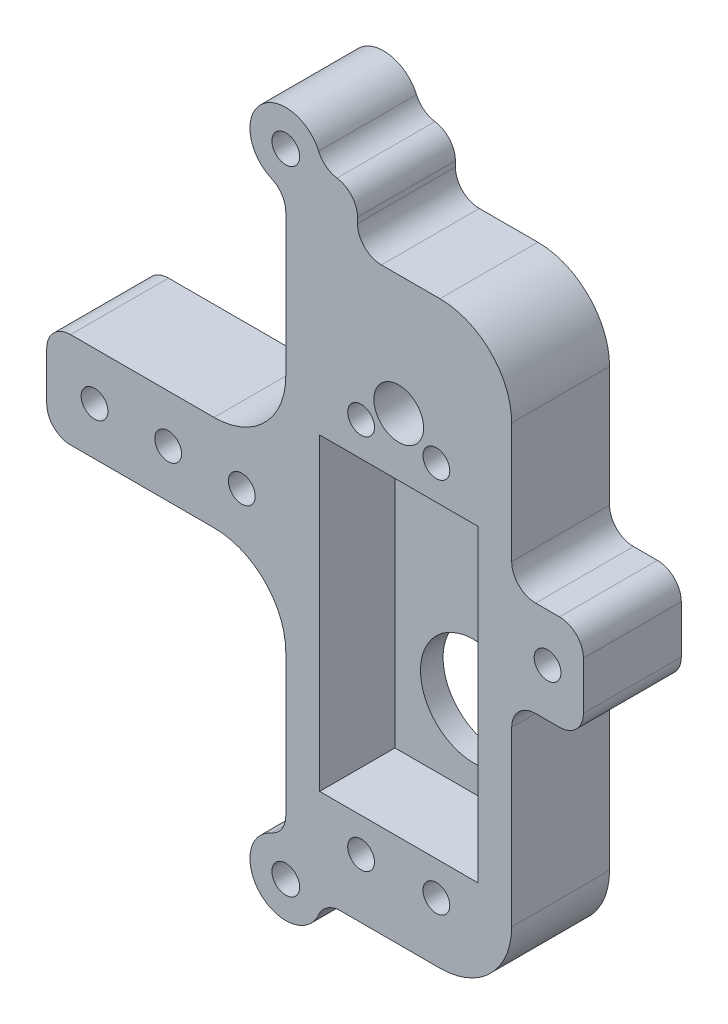
from build123d import *

# Parameters (mm, degrees)
SKETCH1_W               = 31.75
SKETCH1_H               = 12.7
SKETCH1_W_2             = 30
SKETCH1_H_2             = 7
BOSS_EXTRUDE1_DEPTH     = 13
SKETCH4_R               = 1.778
CUT_EXTRUDE3_DEPTH      = 14
SKETCH5_W               = 21
SKETCH5_H               = 41
CUT_EXTRUDE4_DEPTH      = 10
SKETCH6_R               = 7.112
CUT_EXTRUDE5_DEPTH      = 4
SKETCH7_W               = 31.75
SKETCH7_H               = 12.7
CUT_EXTRUDE6_DEPTH      = 6.35
SKETCH10_R              = 1.905
CUT_EXTRUDE8_DEPTH      = 14
SKETCH11_R              = 3.302
CUT_EXTRUDE9_DEPTH      = 9.525
SKETCH13_W              = 9.525
SKETCH13_H              = 12.7
SKETCH13_R              = 1.778
BOSS_EXTRUDE2_DEPTH     = 13
BOSS_EXTRUDE3_DEPTH     = 13
SKETCH18_R              = 1.8415
CUT_EXTRUDE10_DEPTH     = 14
FILLET1_R               = 9.525
FILLET2_R               = 3.175
SKETCH19_W              = 22.225
SKETCH19_H              = 12.7
BOSS_EXTRUDE4_DEPTH     = 7.62
SKETCH8_R               = 1.778
CUT_EXTRUDE7_DEPTH      = 7.35
CUT_EXTRUDE7_DEPTH_BACK = 17.78
FILLET3_R               = 3.175


with BuildPart() as part:
    # Sketch1 → Boss-Extrude1 (new body)
    with BuildSketch(Plane.XY):
        Polygon((31.75, 12.7), (31.75, 0), (31.75, -28.65), (61.75, -28.65), (61.75, 0), (61.75, 12.7), (61.75, 41.35), (31.75, 41.35), align=None)
        with Locations((15.875, 6.35)):
            Rectangle(SKETCH1_W, SKETCH1_H)
        with Locations((46.75, -32.15)):
            Rectangle(SKETCH1_W_2, SKETCH1_H_2)
    extrude(amount=BOSS_EXTRUDE1_DEPTH)

    # Sketch4 → Cut-Extrude3 (cut, through all)
    with BuildSketch(Plane.XY.offset(13)):
        with Locations((41.75, 22.199999832)):
            Circle(SKETCH4_R)
        with Locations((51.75, 22.199999832)):
            Circle(SKETCH4_R)
        with Locations((41.75, -27.800000168)):
            Circle(SKETCH4_R)
        with Locations((51.75, -27.800000168)):
            Circle(SKETCH4_R)
    extrude(amount=-CUT_EXTRUDE3_DEPTH, mode=Mode.SUBTRACT)

    # Sketch5 → Cut-Extrude4 (cut)
    with BuildSketch(Plane.XY.offset(13)):
        with Locations((46.75, -2.800000024)):
            Rectangle(SKETCH5_W, SKETCH5_H)
    extrude(amount=-CUT_EXTRUDE4_DEPTH, mode=Mode.SUBTRACT)

    # Sketch6 → Cut-Extrude5 (cut, through all)
    with BuildSketch(Plane.XY.offset(3)):
        with Locations((46.75, -12.700000168)):
            Circle(SKETCH6_R)
    extrude(amount=-CUT_EXTRUDE5_DEPTH, mode=Mode.SUBTRACT)

    # Sketch7 → Cut-Extrude6 (cut)
    with BuildSketch(Plane(origin=(0, 0, 0), x_dir=(-1, 0, 0), z_dir=(0, 0, -1))):
        with Locations((-15.875, 6.35)):
            Rectangle(SKETCH7_W, SKETCH7_H)
    extrude(amount=-CUT_EXTRUDE6_DEPTH, mode=Mode.SUBTRACT)

    # Sketch10 → Cut-Extrude8 (cut, through all)
    with BuildSketch(Plane(origin=(0, 0, 0), x_dir=(-1, 0, 0), z_dir=(0, 0, -1))):
        with Locations((-46.75, 25.4)):
            Circle(SKETCH10_R)
    extrude(amount=-CUT_EXTRUDE8_DEPTH, mode=Mode.SUBTRACT)

    # Sketch11 → Cut-Extrude9 (cut)
    with BuildSketch(Plane.XY.offset(13)):
        with Locations((46.75, 25.4)):
            Circle(SKETCH11_R)
    extrude(amount=-CUT_EXTRUDE9_DEPTH, mode=Mode.SUBTRACT)

    # Sketch13 → Boss-Extrude2 (add)
    with BuildSketch(Plane.XY.offset(13)):
        with Locations((66.5125, 6.35)):
            Rectangle(SKETCH13_W, SKETCH13_H)
        with Locations((66.5125, 6.35)):
            Circle(SKETCH13_R, mode=Mode.SUBTRACT)
    extrude(amount=-BOSS_EXTRUDE2_DEPTH)

    # Sketch17 → Boss-Extrude3 (add)
    with BuildSketch(Plane.XY.offset(13)):
        with BuildLine():
            ThreePointArc((36.5125, 48.359214074), (28.382403955, 51.726810119), (31.75, 43.596714074))
            Line((31.75, 43.596714074), (31.75, 48.359214074))
            Line((31.75, 48.359214074), (36.5125, 48.359214074))
        make_face()
        with BuildLine():
            Line((31.75, 48.359214074), (31.75, 43.596714074))
            ThreePointArc((31.75, 43.596714074), (35.117596045, 44.991618029), (36.5125, 48.359214074))
            Line((36.5125, 48.359214074), (31.75, 48.359214074))
        make_face()
        with BuildLine():
            Line((31.75, 43.596714074), (31.75, 41.35))
            Line((31.75, 41.35), (41.275, 41.35))
            Line((41.275, 41.35), (41.275, 48.359214074))
            Line((41.275, 48.359214074), (36.5125, 48.359214074))
            ThreePointArc((36.5125, 48.359214074), (35.117596045, 44.991618029), (31.75, 43.596714074))
        make_face()
        with BuildLine():
            Line((31.75, -35.65), (36.5125, -35.65))
            ThreePointArc((36.5125, -35.65), (35.117596045, -32.282403955), (31.75, -30.8875))
            Line((31.75, -30.8875), (31.75, -35.65))
        make_face()
        with BuildLine():
            ThreePointArc((31.75, -30.8875), (28.382403955, -39.017596045), (36.5125, -35.65))
            Line((36.5125, -35.65), (31.75, -35.65))
            Line((31.75, -35.65), (31.75, -30.8875))
        make_face()
    extrude(amount=-BOSS_EXTRUDE3_DEPTH)

    # Sketch18 → Cut-Extrude10 (cut, through all)
    with BuildSketch(Plane.XY.offset(13)):
        with Locations((31.75, -35.65)):
            Circle(SKETCH18_R)
        with Locations((31.75, 48.359214074)):
            Circle(SKETCH18_R)
    extrude(amount=-CUT_EXTRUDE10_DEPTH, mode=Mode.SUBTRACT)

    # Fillet1
    fillet1_edges = [part.edges().sort_by_distance(p)[0] for p in [
        (31.75, 0, 9.675),
        (31.75, 12.7, 9.675),
        (61.75, 41.35, 6.5),
        (61.75, -35.65, 6.5),
    ]]
    fillet(fillet1_edges, radius=FILLET1_R)

    # Fillet2
    fillet2_edges = [part.edges().sort_by_distance(p)[0] for p in [
        (71.275, 0, 6.5),
        (71.275, 12.7, 6.5),
        (61.75, 12.7, 6.5),
        (61.75, 0, 6.5),
        (31.75, -30.8875, 6.5),
        (36.5125, -35.65, 6.5),
        (31.75, 43.596714074, 6.5),
        (41.275, 41.35, 6.5),
        (36.5125, 48.359214074, 6.5),
    ]]
    fillet(fillet2_edges, radius=FILLET2_R)

    # Sketch19 → Boss-Extrude4 (add)
    with BuildSketch(Plane.XY):
        with BuildLine():
            ThreePointArc((31.75, -9.525), (28.960192091, -2.789807909), (22.225, 0))
            Line((22.225, 0), (22.225, 12.7))
            ThreePointArc((22.225, 12.7), (28.960192091, 15.489807909), (31.75, 22.225))
            Line((31.75, 22.225), (31.75, -9.525))
        make_face()
        with Locations((11.1125, 6.35)):
            Rectangle(SKETCH19_W, SKETCH19_H)
    extrude(amount=BOSS_EXTRUDE4_DEPTH)

    # Sketch8 → Cut-Extrude7 (cut, two sides)
    with BuildSketch(Plane(origin=(0, 0, 6.35), x_dir=(-1, 0, 0), z_dir=(0, 0, -1))) as cut_extrude7_sk:
        with Locations((-6.35, 6.35)):
            Circle(SKETCH8_R)
        with Locations((-25.908, 6.35)):
            Circle(SKETCH8_R)
        with Locations((-16.129, 6.35)):
            Circle(SKETCH8_R)
    extrude(amount=CUT_EXTRUDE7_DEPTH, mode=Mode.SUBTRACT)
    extrude(cut_extrude7_sk.sketch, amount=-CUT_EXTRUDE7_DEPTH_BACK, mode=Mode.SUBTRACT)

    # Fillet3
    fillet3_edges = [part.edges().sort_by_distance(p)[0] for p in [
        (41.275, 48.359214074, 6.5),
        (0, 12.7, 6.5),
        (0, 0, 6.5),
    ]]
    fillet(fillet3_edges, radius=FILLET3_R)


solid = part.part
